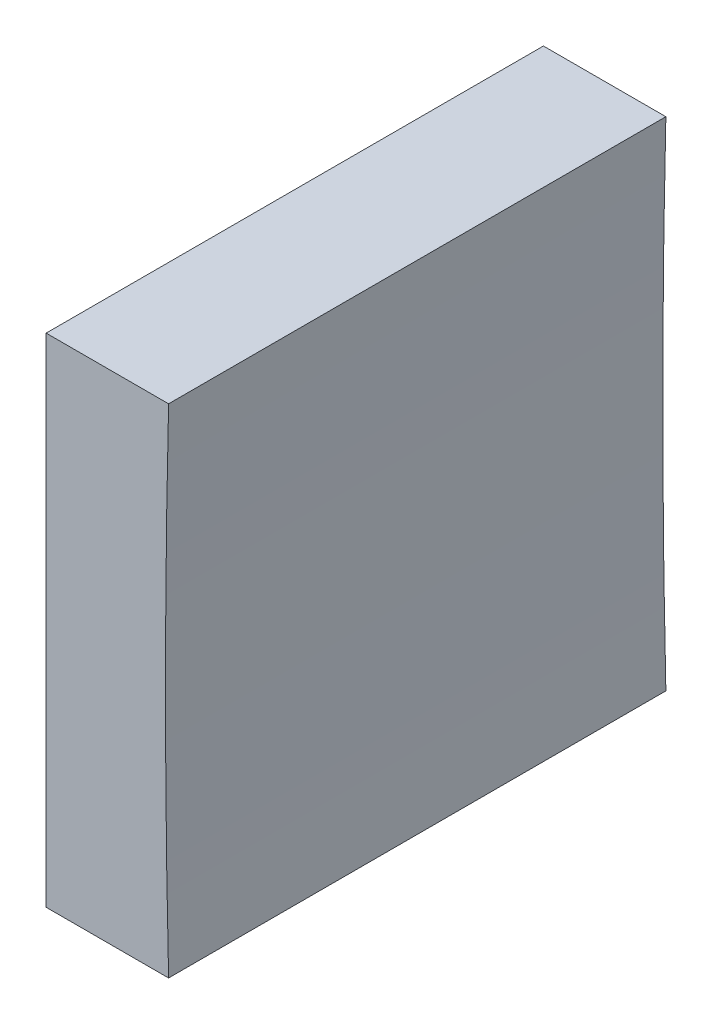
from build123d import *

# Parameters (mm, degrees)
EXTRUDE_1_DEPTH = 25


with BuildPart() as part:
    # 草图1 → 凸台-拉伸1 (new body)
    with BuildSketch(Plane.XY):
        with BuildLine():
            Line((284.707135631, 66.857929268), (284.707135631, 79.357929268))
            Line((284.707135631, 79.357929268), (290.863410041, 79.357929268))
            ThreePointArc((290.863410041, 79.357929268), (290.70713562, 66.857929268), (290.863410041, 54.357929268))
            Line((290.863410041, 54.357929268), (284.707135631, 54.357929268))
            Line((284.707135631, 54.357929268), (284.707135631, 66.857929268))
        make_face()
    extrude(amount=EXTRUDE_1_DEPTH)


solid = part.part
